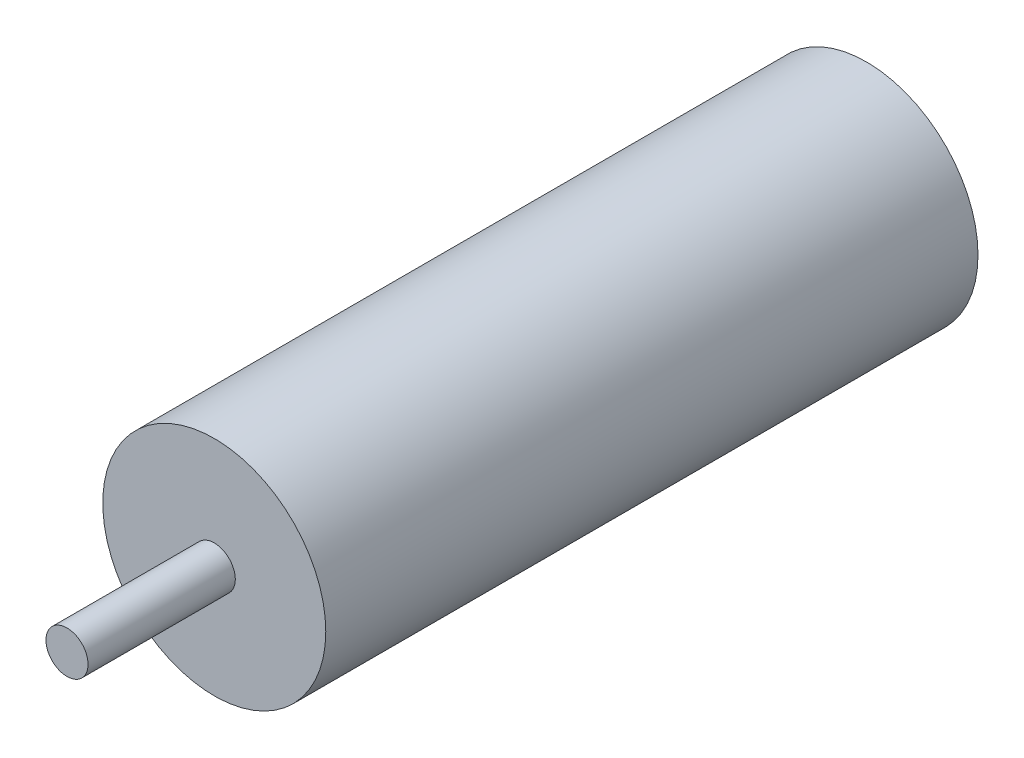
from build123d import *

# Parameters (mm, degrees)
SKETCH1_R      = 5.3
EXTRUDE1_DEPTH = 31
SKETCH2_R      = 1
EXTRUDE2_DEPTH = 7


with BuildPart() as part:
    # Sketch1 → Extrude1 (new body)
    with BuildSketch(Plane.XY):
        Circle(SKETCH1_R)
    extrude(amount=EXTRUDE1_DEPTH)

    # Sketch2 → Extrude2 (add)
    with BuildSketch(Plane.XY.offset(31)):
        Circle(SKETCH2_R)
    extrude(amount=EXTRUDE2_DEPTH)


solid = part.part
